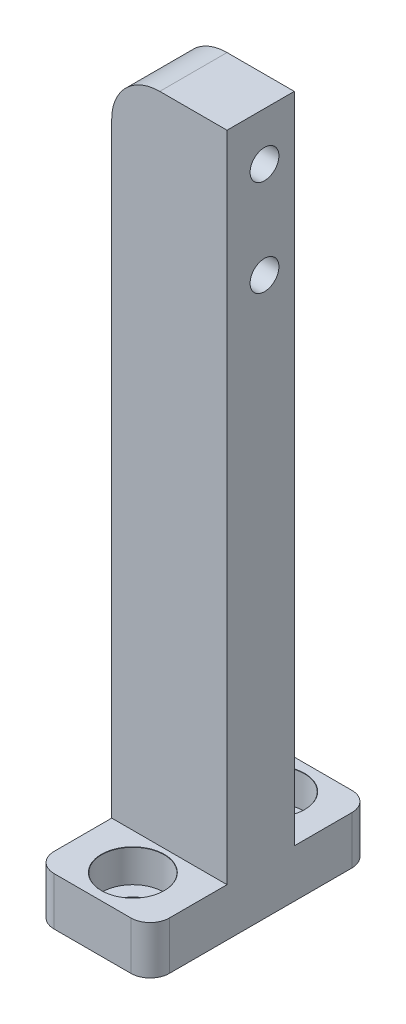
from build123d import *

# Parameters (mm, degrees)
SKETCH1_W           = 12
SKETCH1_H           = 7
BOSS_EXTRUDE1_DEPTH = 36.5
SKETCH3_W           = 12
SKETCH3_H           = 5
BOSS_EXTRUDE2_DEPTH = 11.5
FILLET1_R           = 2
FILLET2_R           = 5
CUT_EXTRUDE1_REACH  = 14
SKETCH7_R           = 1.5


with BuildPart() as part:
    # Sketch1 → Boss-Extrude1 (new body, symmetric)
    with BuildSketch(Plane(origin=(0, 0, 0), x_dir=(1, 0, 0), z_dir=(0, 1, 0))):
        Rectangle(SKETCH1_W, SKETCH1_H)
    extrude(amount=BOSS_EXTRUDE1_DEPTH, both=True)

    # Sketch3 → Boss-Extrude2 (add, symmetric)
    with BuildSketch(Plane.XY):
        with Locations((0, -34)):
            Rectangle(SKETCH3_W, SKETCH3_H)
    extrude(amount=BOSS_EXTRUDE2_DEPTH, both=True)

    # Fillet1
    fillet1_edges = [part.edges().sort_by_distance(p)[0] for p in [
        (-6, -34, -11.5),
        (6, -34, -11.5),
        (-6, -34, 11.5),
        (6, -34, 11.5),
    ]]
    fillet(fillet1_edges, radius=FILLET1_R)

    # Sketch6 → CBORE for M3 Hex Socket Head Cap Screw1 (revolve, cut)
    with BuildSketch(Plane(origin=(0, -31.5, -7.3), x_dir=(0, 0, 1), z_dir=(1, 0, 0))):
        Polygon((0, 0), (0, 5), (1.7, 5), (1.7, 3.4), (3.25, 3.4), (3.25, 0.025), (3.275, 0), align=None)
    cbore_for_m3_hex_socket_head_cap_screw1 = revolve(axis=Axis((0, -25.15, -7.3), (0, -1, 0)), mode=Mode.SUBTRACT)

    # Mirror1: CBORE for M3 Hex Socket Head Cap Screw1 across plane
    add(cbore_for_m3_hex_socket_head_cap_screw1.mirror(Plane.XY), mode=Mode.SUBTRACT)

    # Fillet2
    fillet2_edges = [part.edges().sort_by_distance(p)[0] for p in [
        (-6, 36.5, 0),
    ]]
    fillet(fillet2_edges, radius=FILLET2_R)

    # Sketch7 → Cut-Extrude1 (cut, up to next)
    with BuildSketch(Plane(origin=(6, 0, 0), x_dir=(0, 0, -1), z_dir=(1, 0, 0)), mode=Mode.PRIVATE) as cut_extrude1_sk1:
        with Locations((0.4, 31.5)):
            Circle(SKETCH7_R)
    cut_extrude1_tool1 = extrude(cut_extrude1_sk1.sketch, amount=-CUT_EXTRUDE1_REACH, mode=Mode.PRIVATE) & part.part
    add(cut_extrude1_tool1.solids().sort_by_distance((6, 31.5, -0.4))[0], mode=Mode.SUBTRACT)
    # Sketch7 → Cut-Extrude1 (cut, up to next)
    with BuildSketch(Plane(origin=(6, 0, 0), x_dir=(0, 0, -1), z_dir=(1, 0, 0)), mode=Mode.PRIVATE) as cut_extrude1_sk2:
        with Locations((0.4, 21.5)):
            Circle(SKETCH7_R)
    cut_extrude1_tool2 = extrude(cut_extrude1_sk2.sketch, amount=-CUT_EXTRUDE1_REACH, mode=Mode.PRIVATE) & part.part
    add(cut_extrude1_tool2.solids().sort_by_distance((6, 21.5, -0.4))[0], mode=Mode.SUBTRACT)


solid = part.part
